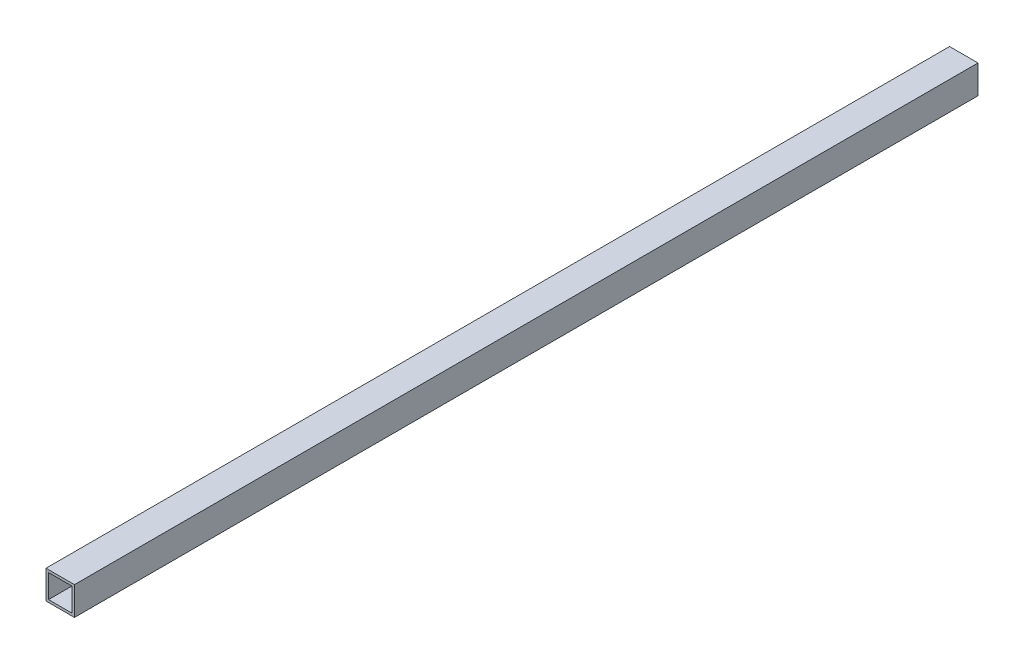
from build123d import *

# Parameters (mm, degrees)
SKETCH1_W           = 17
SKETCH1_H           = 17
SKETCH1_W_2         = 14
SKETCH1_H_2         = 14
BOSS_EXTRUDE1_DEPTH = 540


with BuildPart() as part:
    # Sketch1 → Boss-Extrude1 (new body)
    with BuildSketch(Plane.XY):
        Rectangle(SKETCH1_W, SKETCH1_H)
        Rectangle(SKETCH1_W_2, SKETCH1_H_2, mode=Mode.SUBTRACT)
    extrude(amount=BOSS_EXTRUDE1_DEPTH)


solid = part.part
